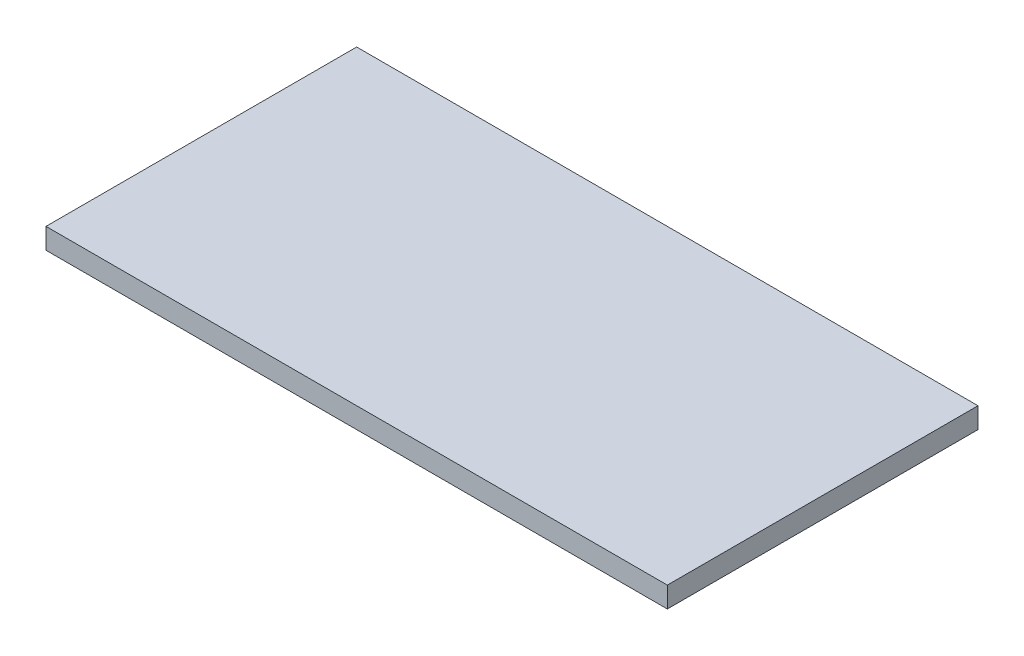
from build123d import *

# Parameters (mm, degrees)
SKETCH1_W           = 300
SKETCH1_H           = 150
BOSS_EXTRUDE1_DEPTH = 10


with BuildPart() as part:
    # Sketch1 → Boss-Extrude1 (new body)
    with BuildSketch(Plane(origin=(0, 0, 0), x_dir=(1, 0, 0), z_dir=(0, 1, 0))):
        with Locations((150, 75)):
            Rectangle(SKETCH1_W, SKETCH1_H)
    extrude(amount=BOSS_EXTRUDE1_DEPTH)


solid = part.part
